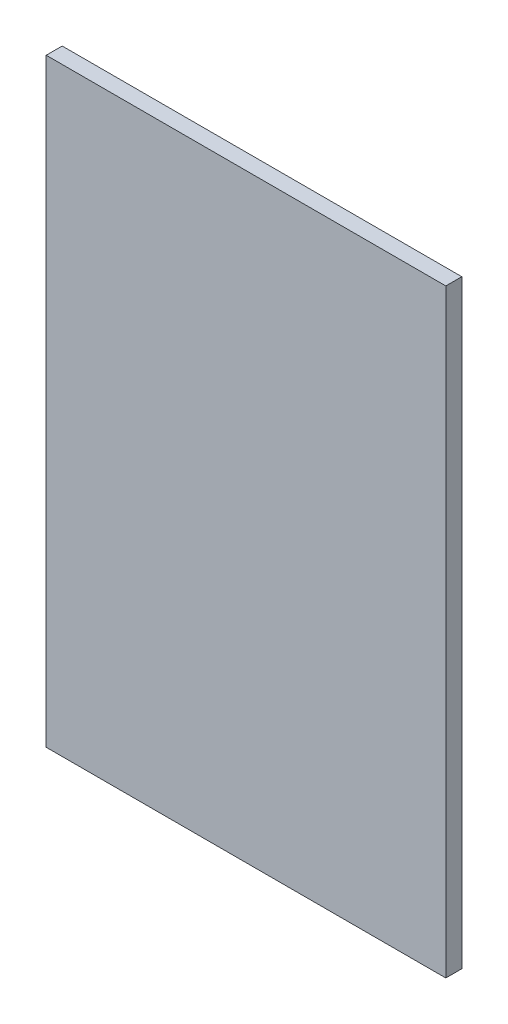
from build123d import *

# Parameters (mm, degrees)
SKETCH1_W           = 100
SKETCH1_H           = 150
BOSS_EXTRUDE1_DEPTH = 4


with BuildPart() as part:
    # Sketch1 → Boss-Extrude1 (new body)
    with BuildSketch(Plane.XY):
        with Locations((50, 75)):
            Rectangle(SKETCH1_W, SKETCH1_H)
    extrude(amount=BOSS_EXTRUDE1_DEPTH)


solid = part.part
